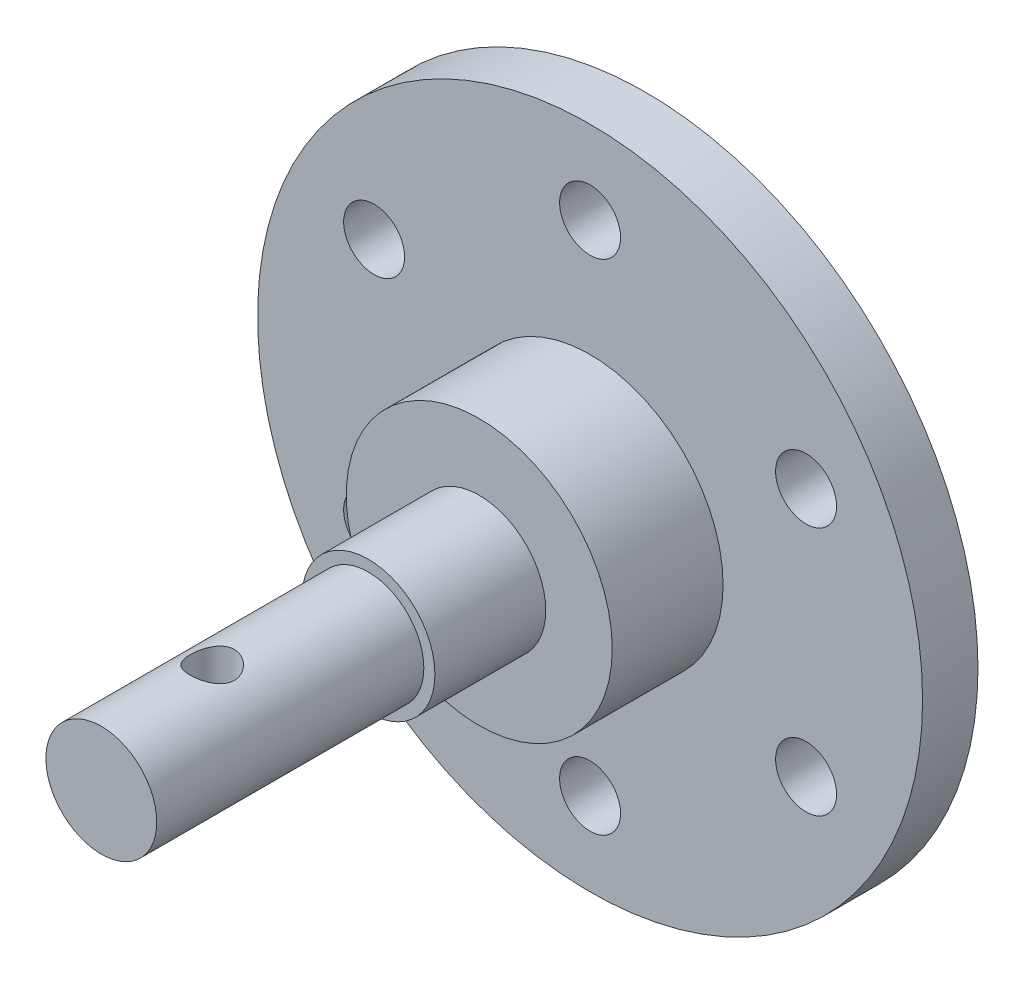
from build123d import *

# Parameters (mm, degrees)
SKETCH_1_R               = 30
SKETCH_1_R_2             = 2.75
EXTRUDE_1_DEPTH          = 5
SKETCH_2_R               = 12
EXTRUDE_2_DEPTH          = 10
SKETCH_3_R               = 6
EXTRUDE_3_DEPTH          = 10
SKETCH_5_R               = 5
EXTRUDE_4_DEPTH          = 24.1
CUT_EXTRUDE_1_DEPTH      = 10
CUT_EXTRUDE_1_DEPTH_BACK = 10
SKETCH_6_R               = 2


with BuildPart() as part:
    # 草图1 → 凸台-拉伸1 (new body)
    with BuildSketch(Plane.XY):
        Circle(SKETCH_1_R)
        with Locations((0, 22.5)):
            Circle(SKETCH_1_R_2, mode=Mode.SUBTRACT)
        with Locations((19.485571585, 11.25)):
            Circle(SKETCH_1_R_2, mode=Mode.SUBTRACT)
        with Locations((19.485571585, -11.25)):
            Circle(SKETCH_1_R_2, mode=Mode.SUBTRACT)
        with Locations((0, -22.5)):
            Circle(SKETCH_1_R_2, mode=Mode.SUBTRACT)
        with Locations((-19.485571585, -11.25)):
            Circle(SKETCH_1_R_2, mode=Mode.SUBTRACT)
        with Locations((-19.485571585, 11.25)):
            Circle(SKETCH_1_R_2, mode=Mode.SUBTRACT)
    extrude(amount=EXTRUDE_1_DEPTH)

    # 草图2 → 凸台-拉伸2 (add)
    with BuildSketch(Plane.XY.offset(5)):
        Circle(SKETCH_2_R)
    extrude(amount=EXTRUDE_2_DEPTH)

    # 草图3 → 凸台-拉伸3 (add)
    with BuildSketch(Plane.XY.offset(15)):
        Circle(SKETCH_3_R)
    extrude(amount=EXTRUDE_3_DEPTH)

    # 草图5 → 凸台-拉伸4 (add)
    with BuildSketch(Plane.XY.offset(25)):
        Circle(SKETCH_5_R)
    extrude(amount=EXTRUDE_4_DEPTH)

    # 草图6 → 切除-拉伸1 (cut, two sides: drawn at the far end of the back side and taken through both)
    with BuildSketch(Plane(origin=(0, 0, 0), x_dir=(1, 0, 0), z_dir=(0, 1, 0)).offset(-CUT_EXTRUDE_1_DEPTH_BACK)):
        with Locations((0, -39.1)):
            Circle(SKETCH_6_R)
    extrude(amount=CUT_EXTRUDE_1_DEPTH + CUT_EXTRUDE_1_DEPTH_BACK, mode=Mode.SUBTRACT)


solid = part.part
